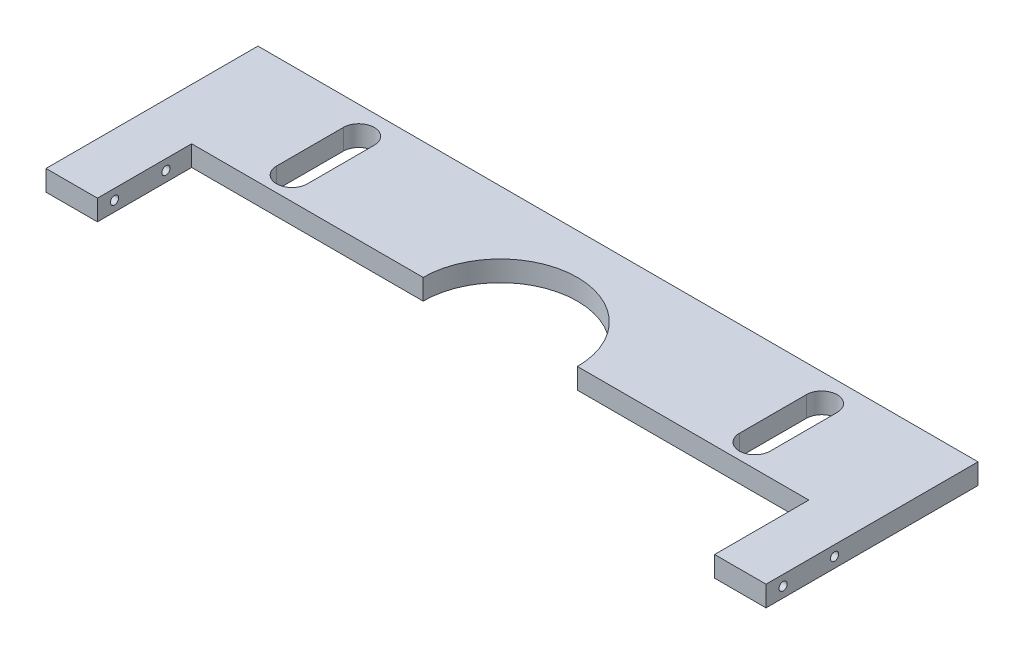
from build123d import *

# Parameters (mm, degrees)
SKETCH2_W                      = 140
SKETCH2_H                      = 38.89
BOSS_EXTRUDE1_DEPTH            = 4
M2X0_4_TAPPED_HOLE1_AT_2_COUNT = 2
M2X0_4_TAPPED_HOLE1_AT_2_PITCH = 10
SKETCH6_W                      = 120
SKETCH6_H                      = 20
CUT_EXTRUDE1_DEPTH             = 5
SKETCH8_W                      = 35
SKETCH8_H                      = 2.29
SKETCH8_W_2                    = 10
BOSS_EXTRUDE2_DEPTH            = 4
SKETCH9_W                      = 25
SKETCH9_H                      = 2.29
CUT_EXTRUDE3_DEPTH             = 5
SKETCH10_W                     = 140
SKETCH10_H                     = 4
BOSS_EXTRUDE3_DEPTH            = 4
SKETCH11_W                     = 140
SKETCH11_H                     = 3.97
CUT_EXTRUDE4_DEPTH             = 10
CUT_EXTRUDE5_DEPTH             = 5
CUT_EXTRUDE6_DEPTH             = 10


with BuildPart() as part:
    # Sketch2 → Boss-Extrude1 (new body)
    with BuildSketch(Plane(origin=(0, 0, 0), x_dir=(1, 0, 0), z_dir=(0, 1, 0))):
        Rectangle(SKETCH2_W, SKETCH2_H)
    extrude(amount=BOSS_EXTRUDE1_DEPTH)

    # Sketch4 → M2x0.4 Tapped Hole1 (revolve, cut)
    with BuildSketch(Plane(origin=(-70, 2, 4.445), x_dir=(0, 0, 1), z_dir=(0, 1, 0))):
        Polygon((0, 0), (0, 18.480688495), (0.8, 18), (0.8, 0), align=None)
    m2x0_4_tapped_hole1 = revolve(axis=Axis((-76.35, 2, 4.445), (1, 0, 0)), mode=Mode.SUBTRACT)

    # M2x0.4 Tapped Hole1 at 2: M2x0.4 Tapped Hole1 ×2
    with Locations(*[(0, 0, i * M2X0_4_TAPPED_HOLE1_AT_2_PITCH) for i in range(1, M2X0_4_TAPPED_HOLE1_AT_2_COUNT)]):
        add(m2x0_4_tapped_hole1, mode=Mode.SUBTRACT)

    # Mirror1: M2x0.4 Tapped Hole1 across plane
    add(m2x0_4_tapped_hole1.mirror(Plane(origin=(0, 0, 0), x_dir=(0, 0, 1), z_dir=(1, 0, 0))), mode=Mode.SUBTRACT)

    # Mirror1 copy 1 sketch → Mirror1 copy 1 (revolve, cut)
    with BuildSketch(Plane(origin=(70, 2, 14.445), x_dir=(0, 0, 1), z_dir=(0, 1, 0))):
        Polygon((0, 0), (0, -18.480688495), (0.8, -18), (0.8, 0), align=None)
    revolve(axis=Axis((76.35, 2, 14.445), (1, 0, 0)), mode=Mode.SUBTRACT)

    # Sketch6 → Cut-Extrude1 (cut, through all)
    with BuildSketch(Plane(origin=(0, 4, 0), x_dir=(1, 0, 0), z_dir=(0, 1, 0))):
        with Locations((0, -9.445)):
            Rectangle(SKETCH6_W, SKETCH6_H)
    extrude(amount=-CUT_EXTRUDE1_DEPTH, mode=Mode.SUBTRACT)

    # Sketch8 → Boss-Extrude2 (add, through all)
    with BuildSketch(Plane(origin=(0, 4, 0), x_dir=(1, 0, 0), z_dir=(0, 1, 0))):
        with Locations((-52.5, -20.59)):
            Rectangle(SKETCH8_W, SKETCH8_H)
        with Locations((65, -20.59)):
            Rectangle(SKETCH8_W_2, SKETCH8_H)
    extrude(amount=-BOSS_EXTRUDE2_DEPTH)

    # Sketch9 → Cut-Extrude3 (cut, through all)
    with BuildSketch(Plane(origin=(0, 4, 0), x_dir=(1, 0, 0), z_dir=(0, 1, 0))):
        with Locations((-47.5, -20.59)):
            Rectangle(SKETCH9_W, SKETCH9_H)
    extrude(amount=-CUT_EXTRUDE3_DEPTH, mode=Mode.SUBTRACT)

    # Sketch10 → Boss-Extrude3 (add, through all)
    with BuildSketch(Plane(origin=(0, 4, 0), x_dir=(1, 0, 0), z_dir=(0, 1, 0))):
        with Locations((0, 21.445)):
            Rectangle(SKETCH10_W, SKETCH10_H)
    extrude(amount=-BOSS_EXTRUDE3_DEPTH)

    # Sketch11 → Cut-Extrude4 (cut)
    with BuildSketch(Plane(origin=(0, 4, 0), x_dir=(1, 0, 0), z_dir=(0, 1, 0))):
        with Locations((0, -19.75)):
            Rectangle(SKETCH11_W, SKETCH11_H)
    extrude(amount=-CUT_EXTRUDE4_DEPTH, mode=Mode.SUBTRACT)

    # Sketch7 → Cut-Extrude5 (cut, through all)
    with BuildSketch(Plane(origin=(0, 4, 0), x_dir=(1, 0, 0), z_dir=(0, 1, 0))):
        with BuildLine():
            Line((-42, 18.055), (-42, 5.055))
            ThreePointArc((-42, 5.055), (-45, 2.055), (-48, 5.055))
            Line((-48, 5.055), (-48, 18.055))
            ThreePointArc((-48, 18.055), (-45, 21.055), (-42, 18.055))
        make_face()
        with BuildLine():
            Line((48, 18.055), (48, 5.055))
            ThreePointArc((48, 5.055), (45, 2.055), (42, 5.055))
            Line((42, 5.055), (42, 18.055))
            ThreePointArc((42, 18.055), (45, 21.055), (48, 18.055))
        make_face()
    extrude(amount=-CUT_EXTRUDE5_DEPTH, mode=Mode.SUBTRACT)

    # Sketch13 → Cut-Extrude6 (cut)
    with BuildSketch(Plane(origin=(0, 4, 0), x_dir=(1, 0, 0), z_dir=(0, 1, 0))):
        with BuildLine():
            Line((-15, 0.555), (15, 0.555))
            ThreePointArc((15, 0.555), (0, 15.555), (-15, 0.555))
        make_face()
    extrude(amount=-CUT_EXTRUDE6_DEPTH, mode=Mode.SUBTRACT)


solid = part.part
